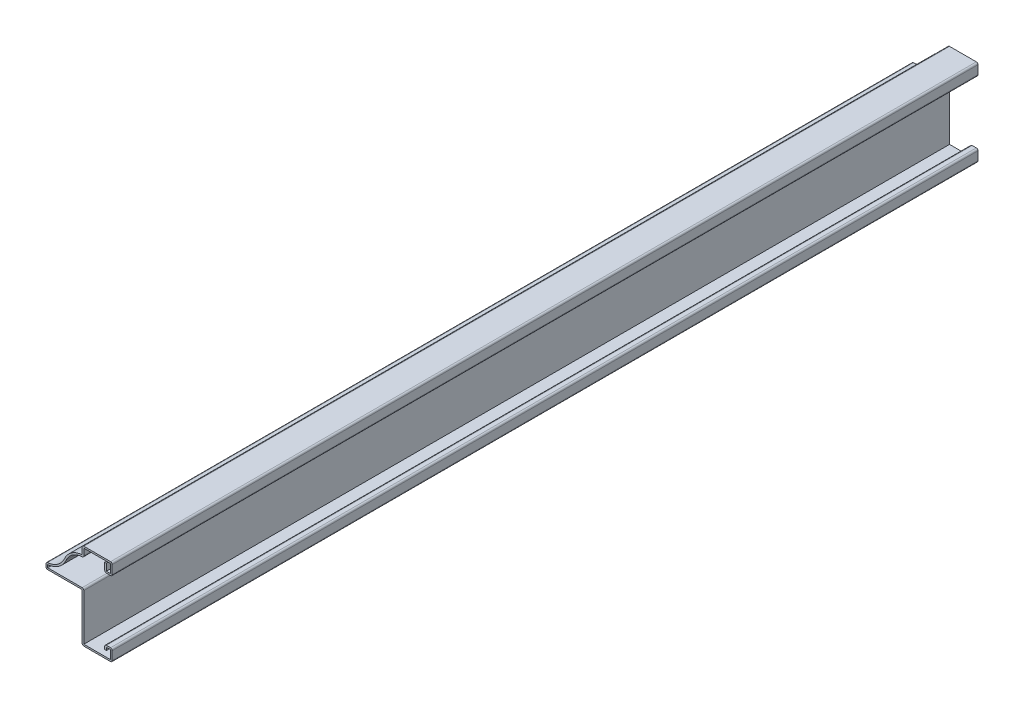
from build123d import *

# Parameters (mm, degrees)
EXTRUDE_THIN1_DEPTH = 456.40625
FILLET1_R           = 0.889


with BuildPart() as part:
    # Sketch1 → Extrude-Thin1 (new body)
    with BuildSketch(Plane.XY):
        with BuildLine():
            Line((-3.96875, 3.96875), (-3.96875, 6.35))
            Line((-3.96875, 6.35), (0, 6.35))
            Line((0, 6.35), (0, 0))
            Line((0, 0), (-15.875, 0))
            Line((-15.875, 0), (-15.875, 25.4))
            Line((-15.875, 25.4), (-34.925, 25.4))
            Line((-34.925, 25.4), (-34.925, 28.575))
            ThreePointArc((-34.925, 28.575), (-29.089166411, 30.303541744), (-25.13609411, 34.931503458))
            ThreePointArc((-25.13609411, 34.931503458), (-21.402652939, 39.412968218), (-15.875, 41.275))
            Line((-15.875, 41.275), (-15.875, 45.640625))
            Line((-15.875, 45.640625), (0, 45.640625))
            Line((0, 45.640625), (0, 39.290625))
            Line((0, 39.290625), (-3.96875, 39.290625))
            Line((-3.96875, 39.290625), (-3.96875, 43.862625))
            Line((-3.96875, 43.862625), (-3.07975, 43.862625))
            Line((-3.07975, 43.862625), (-3.07975, 40.179625))
            Line((-3.07975, 40.179625), (-0.889, 40.179625))
            Line((-0.889, 40.179625), (-0.889, 44.751625))
            Line((-0.889, 44.751625), (-14.986, 44.751625))
            Line((-14.986, 44.751625), (-14.986, 40.39236674))
            ThreePointArc((-14.986, 40.39236674), (-20.546471616, 38.910847666), (-24.323977473, 34.569857819))
            ThreePointArc((-24.323977473, 34.569857819), (-28.236581443, 29.80735665), (-34.036, 27.720102091))
            Line((-34.036, 27.720102091), (-34.036, 26.289))
            Line((-34.036, 26.289), (-14.986, 26.289))
            Line((-14.986, 26.289), (-14.986, 0.889))
            Line((-14.986, 0.889), (-0.889, 0.889))
            Line((-0.889, 0.889), (-0.889, 5.461))
            Line((-0.889, 5.461), (-3.07975, 5.461))
            Line((-3.07975, 5.461), (-3.07975, 3.96875))
            Line((-3.07975, 3.96875), (-3.96875, 3.96875))
        make_face()
    extrude(amount=-EXTRUDE_THIN1_DEPTH)

    # Fillet1
    fillet1_edges = [part.edges().sort_by_distance(p)[0] for p in [
        (-14.986, 40.39236674, -228.203125),
        (-14.986, 26.289, -228.203125),
        (-3.96875, 6.35, -228.203125),
        (0, 6.35, -228.203125),
        (0, 0, -228.203125),
        (-15.875, 0, -228.203125),
        (-34.925, 25.4, -228.203125),
        (-34.925, 28.575, -228.203125),
        (-15.875, 45.640625, -228.203125),
        (0, 45.640625, -228.203125),
        (0, 39.290625, -228.203125),
        (-3.96875, 39.290625, -228.203125),
    ]]
    fillet(fillet1_edges, radius=FILLET1_R)


solid = part.part
